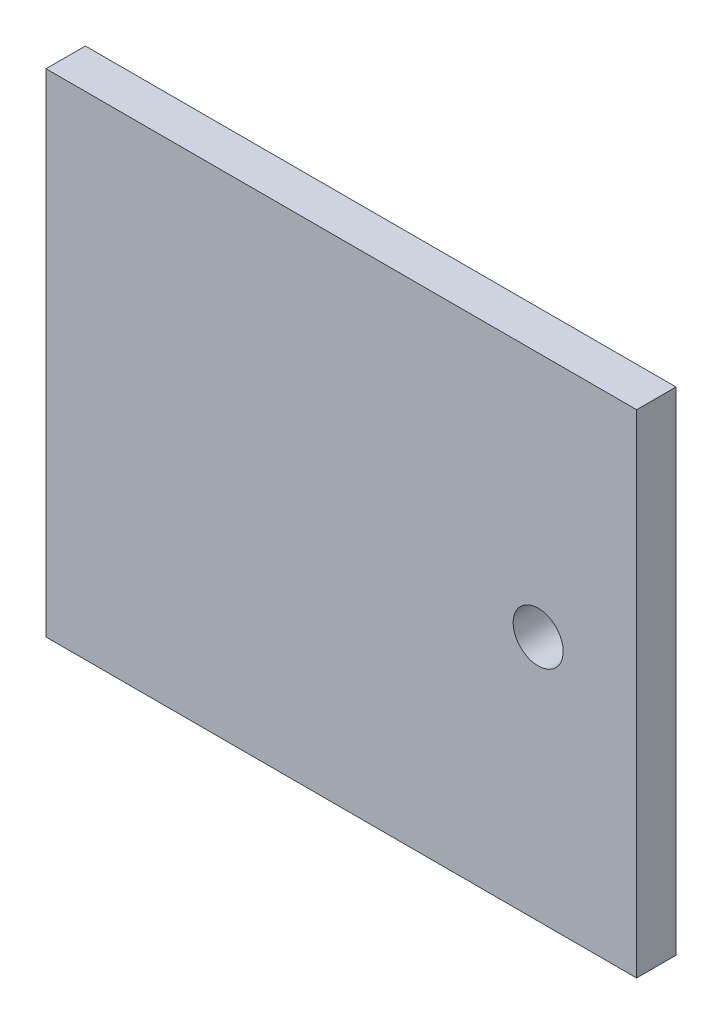
from build123d import *

# Parameters (mm, degrees)
SKETCH1_W           = 300
SKETCH1_H           = 250
BOSS_EXTRUDE1_DEPTH = 20
SKETCH2_R           = 12.7
CUT_EXTRUDE1_DEPTH  = 20


with BuildPart() as part:
    # Sketch1 → Boss-Extrude1 (new body)
    with BuildSketch(Plane.XY):
        Rectangle(SKETCH1_W, SKETCH1_H)
    extrude(amount=BOSS_EXTRUDE1_DEPTH)

    # Sketch2 → Cut-Extrude1 (cut)
    with BuildSketch(Plane.XY.offset(20)):
        with Locations((100, 0)):
            Circle(SKETCH2_R)
    extrude(amount=-CUT_EXTRUDE1_DEPTH, mode=Mode.SUBTRACT)


solid = part.part
